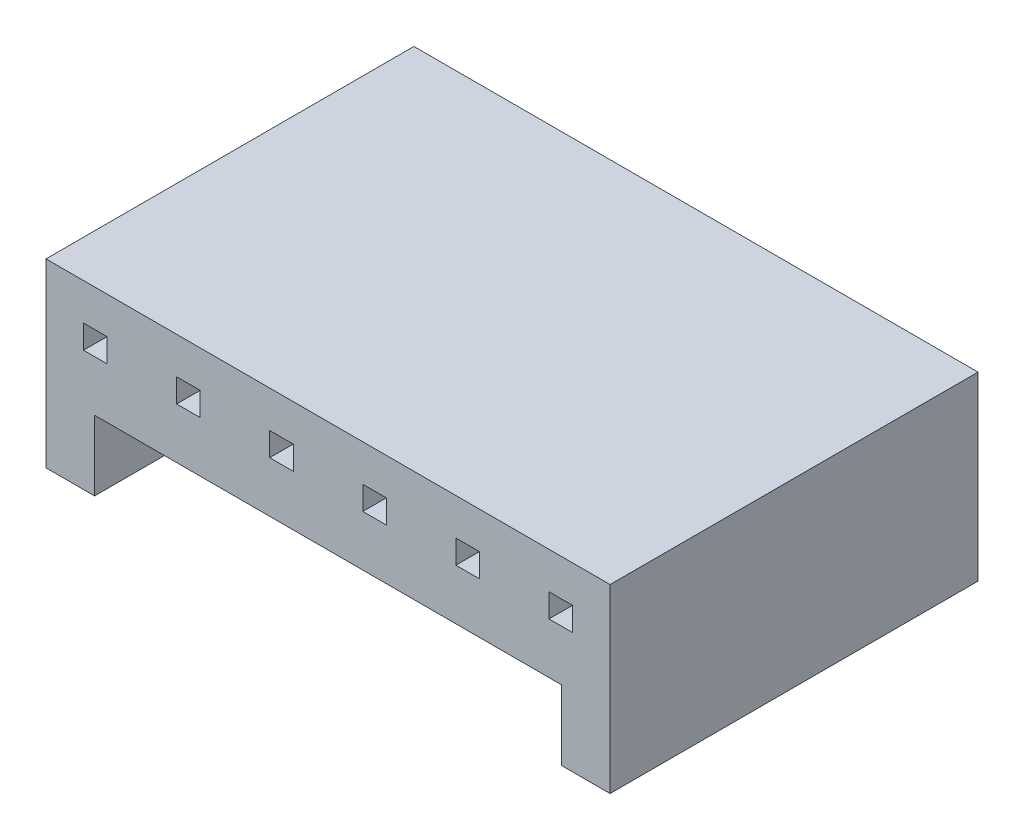
from build123d import *

# Parameters (mm, degrees)
SKETCH1_W           = 0.64
SKETCH1_H           = 0.64
BOSS_EXTRUDE1_DEPTH = 10


with BuildPart() as part:
    # Sketch1 → Boss-Extrude1 (new body)
    with BuildSketch(Plane.XY):
        Polygon((-43.035822511, -34.655658229), (-43.035822511, -39.575658229), (-41.715822511, -39.575658229), (-41.715822511, -37.675658229), (-29.025822511, -37.675658229), (-29.025822511, -39.575658229), (-27.705822511, -39.575658229), (-27.705822511, -34.655658229), align=None)
        with Locations((-39.165822511, -35.975658229)):
            Rectangle(SKETCH1_W, SKETCH1_H, mode=Mode.SUBTRACT)
        with Locations((-41.695822511, -35.975658229)):
            Rectangle(SKETCH1_W, SKETCH1_H, mode=Mode.SUBTRACT)
        with Locations((-36.635822511, -35.975658229)):
            Rectangle(SKETCH1_W, SKETCH1_H, mode=Mode.SUBTRACT)
        with Locations((-34.105822511, -35.975658229)):
            Rectangle(SKETCH1_W, SKETCH1_H, mode=Mode.SUBTRACT)
        with Locations((-31.575822511, -35.975658229)):
            Rectangle(SKETCH1_W, SKETCH1_H, mode=Mode.SUBTRACT)
        with Locations((-29.045822511, -35.975658229)):
            Rectangle(SKETCH1_W, SKETCH1_H, mode=Mode.SUBTRACT)
    extrude(amount=BOSS_EXTRUDE1_DEPTH)


solid = part.part
